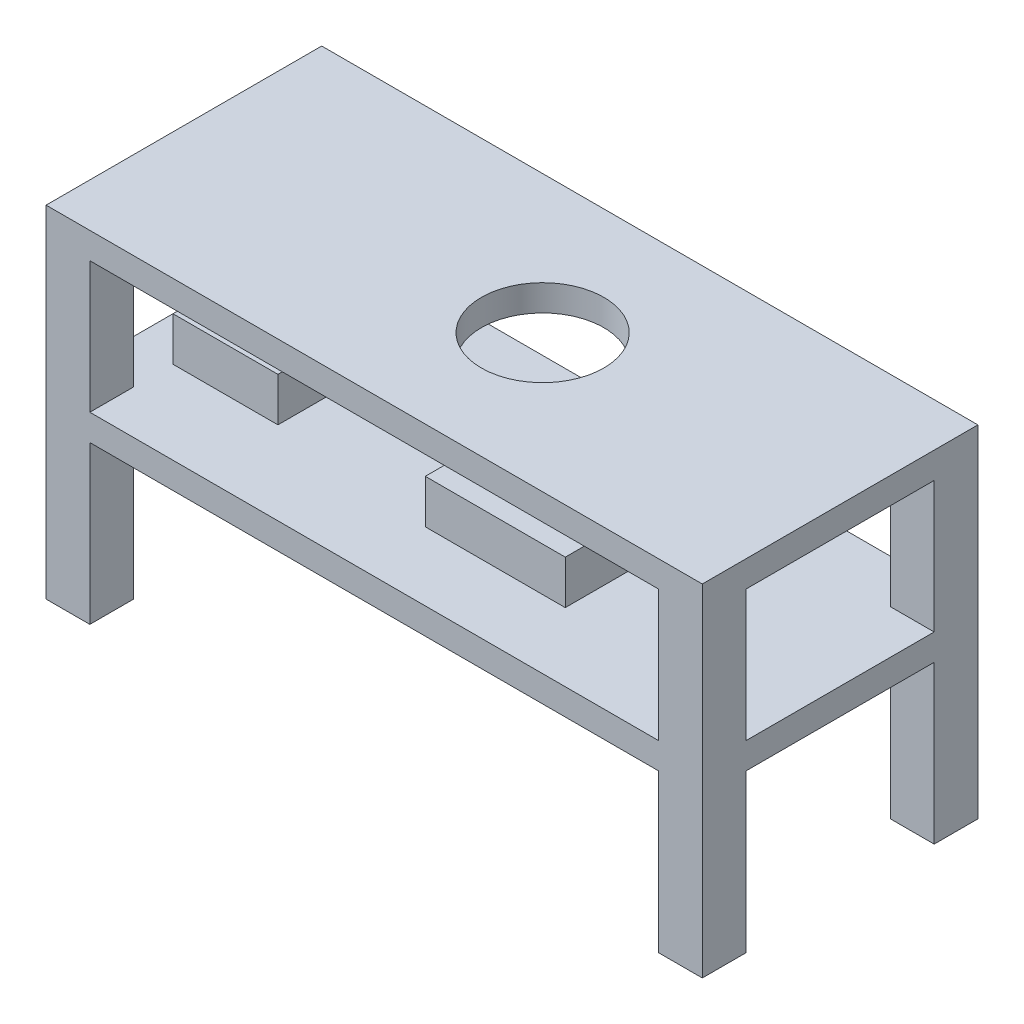
from build123d import *

# Parameters (mm, degrees)
SKETCH1_W           = 1905
SKETCH1_H           = 800.1
BOSS_EXTRUDE1_DEPTH = 76.2
BOSS_EXTRUDE2_START = 457.2
SKETCH2_W           = 1905
SKETCH2_H           = 800.1
BOSS_EXTRUDE2_DEPTH = 76.2
SKETCH3_W           = 127
SKETCH3_H           = 127
BOSS_EXTRUDE3_DEPTH = 990.6
SKETCH4_R           = 177.8
CUT_EXTRUDE1_DEPTH  = 76.2
SKETCH5_W           = 406.4
SKETCH5_H           = 406.4
CONTROL_BOX_DEPTH   = 127
SKETCH6_W           = 304.8
SKETCH6_H           = 304.8
SPECTROMETER_DEPTH  = 127


with BuildPart() as part:
    # Sketch1 → Boss-Extrude1 (new body)
    with BuildSketch(Plane(origin=(0, 0, 0), x_dir=(1, 0, 0), z_dir=(0, 1, 0))):
        Rectangle(SKETCH1_W, SKETCH1_H)
    extrude(amount=BOSS_EXTRUDE1_DEPTH)



with BuildPart() as body_2:
    # Sketch2 → Boss-Extrude2 (new body)
    with BuildSketch(Plane.XZ.offset(-76.2).offset(BOSS_EXTRUDE2_START)):
        Rectangle(SKETCH2_W, SKETCH2_H)
    extrude(amount=BOSS_EXTRUDE2_DEPTH)


with BuildPart() as part_1:
    add(part.part)

    add(body_2.part)  # Boss-Extrude3 merges body 2
    # Sketch3 → Boss-Extrude3 (add)
    with BuildSketch(Plane(origin=(0, 76.2, 0), x_dir=(1, 0, 0), z_dir=(0, 1, 0))):
        with Locations((-889, -336.55)):
            Rectangle(SKETCH3_W, SKETCH3_H)
        with Locations((889, 336.55)):
            Rectangle(SKETCH3_W, SKETCH3_H)
        with Locations((-889, 336.55)):
            Rectangle(SKETCH3_W, SKETCH3_H)
        with Locations((889, -336.55)):
            Rectangle(SKETCH3_W, SKETCH3_H)
    extrude(amount=-BOSS_EXTRUDE3_DEPTH)

    # Sketch4 → Cut-Extrude1 (cut)
    with BuildSketch(Plane(origin=(0, 76.2, 0), x_dir=(1, 0, 0), z_dir=(0, 1, 0))):
        with Locations((88.9, 0)):
            Circle(SKETCH4_R)
    extrude(amount=-CUT_EXTRUDE1_DEPTH, mode=Mode.SUBTRACT)

    # Sketch5 → Control Box (add)
    with BuildSketch(Plane(origin=(0, -381, 0), x_dir=(1, 0, 0), z_dir=(0, 1, 0))):
        with Locations((152.685371452, 1.975779164)):
            Rectangle(SKETCH5_W, SKETCH5_H)
    extrude(amount=CONTROL_BOX_DEPTH)

    # Sketch6 → Spectrometer (add)
    with BuildSketch(Plane(origin=(0, -381, 0), x_dir=(1, 0, 0), z_dir=(0, 1, 0))):
        with Locations((-673.1, -6.35)):
            Rectangle(SKETCH6_W, SKETCH6_H)
    extrude(amount=SPECTROMETER_DEPTH)


solid = part_1.part
